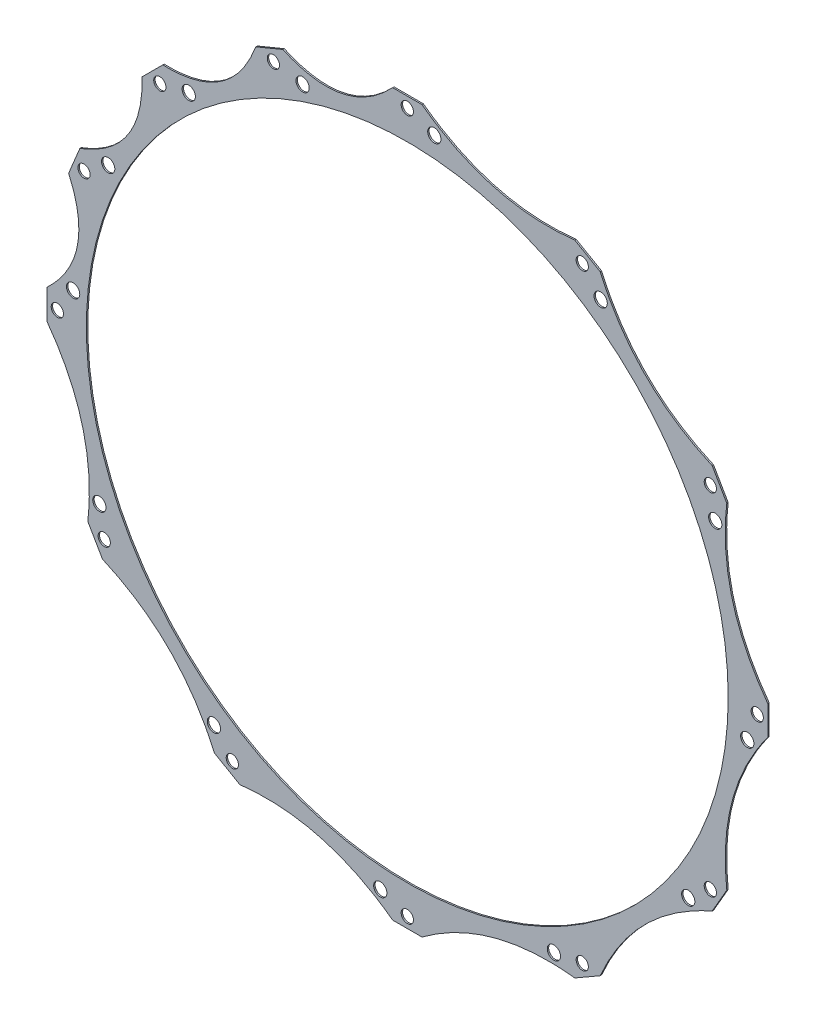
from build123d import *

# Parameters (mm, degrees)
SKETCH4_R           = 169.4688
SKETCH4_R_2         = 3.2385
BOSS_EXTRUDE2_DEPTH = 0.75
SKETCH8_R           = 3.5
CUT_EXTRUDE2_DEPTH  = 1.7500001


with BuildPart() as part:
    # Sketch4 → Boss-Extrude2 (new body)
    with BuildSketch(Plane.XY):
        with BuildLine():
            Line((-7.735342369, 190.342886598), (7.735342369, 190.342886598))
            add(Edge.make_bspline(
                [(7.735342369, 190.342886598), (43.849986057, 163.650375876), (88.472440301, 168.709446408)],
                knots=[0, 0, 0, 1, 1, 1], degree=2))
            Line((88.472440301, 168.709446408), (101.870446297, 160.974104039))
            add(Edge.make_bspline(
                [(101.870446297, 160.974104039), (119.800389819, 119.800389819), (160.974104039, 101.870446297)],
                knots=[0, 0, 0, 1, 1, 1], degree=2))
            Line((160.974104039, 101.870446297), (168.709446408, 88.472440301))
            add(Edge.make_bspline(
                [(168.709446408, 88.472440301), (163.650375876, 43.849986057), (190.342886598, 7.735342369)],
                knots=[0, 0, 0, 1, 1, 1], degree=2))
            Line((190.342886598, 7.735342369), (190.342886598, -7.735342369))
            add(Edge.make_bspline(
                [(190.342886598, -7.735342369), (163.650375876, -43.849986057), (168.709446408, -88.472440301)],
                knots=[0, 0, 0, 1, 1, 1], degree=2))
            Line((168.709446408, -88.472440301), (160.974104039, -101.870446297))
            add(Edge.make_bspline(
                [(160.974104039, -101.870446297), (119.800389819, -119.800389819), (101.870446297, -160.974104039)],
                knots=[0, 0, 0, 1, 1, 1], degree=2))
            Line((101.870446297, -160.974104039), (88.472440301, -168.709446408))
            add(Edge.make_bspline(
                [(88.472440301, -168.709446408), (43.849986057, -163.650375876), (7.735342369, -190.342886598)],
                knots=[0, 0, 0, 1, 1, 1], degree=2))
            Line((7.735342369, -190.342886598), (-7.735342369, -190.342886598))
            add(Edge.make_bspline(
                [(-7.735342369, -190.342886598), (-43.849986057, -163.650375876), (-88.472440301, -168.709446408)],
                knots=[0, 0, 0, 1, 1, 1], degree=2))
            Line((-88.472440301, -168.709446408), (-101.870446297, -160.974104039))
            add(Edge.make_bspline(
                [(-101.870446297, -160.974104039), (-119.800389819, -119.800389819), (-160.974104039, -101.870446297)],
                knots=[0, 0, 0, 1, 1, 1], degree=2))
            Line((-160.974104039, -101.870446297), (-168.709446408, -88.472440301))
            add(Edge.make_bspline(
                [(-168.709446408, -88.472440301), (-163.650375876, -43.849986057), (-190.342886598, -7.735342369)],
                knots=[0, 0, 0, 1, 1, 1], degree=2))
            Line((-190.342886598, -7.735342369), (-190.342886598, 7.735342369))
            add(Edge.make_bspline(
                [(-190.342886598, 7.735342369), (-163.877360858, 32.597233808), (-178.814084455, 65.694544678)],
                knots=[0, 0, 0, 1, 1, 1], degree=2))
            Line((-178.814084455, 65.694544678), (-172.893709719, 79.987593661))
            add(Edge.make_bspline(
                [(-172.893709719, 79.987593661), (-138.92851822, 92.829068072), (-140.062458908, 129.12303282)],
                knots=[0, 0, 0, 1, 1, 1], degree=2))
            Line((-140.062458908, 129.12303282), (-129.12303282, 140.062458908))
            add(Edge.make_bspline(
                [(-129.12303282, 140.062458908), (-92.829068072, 138.92851822), (-79.987593661, 172.893709719)],
                knots=[0, 0, 0, 1, 1, 1], degree=2))
            Line((-79.987593661, 172.893709719), (-65.694544678, 178.814084455))
            add(Edge.make_bspline(
                [(-65.694544678, 178.814084455), (-32.597233808, 163.877360858), (-7.735342369, 190.342886598)],
                knots=[0, 0, 0, 1, 1, 1], degree=2))
        make_face()
        Circle(SKETCH4_R, mode=Mode.SUBTRACT)
        with Locations((0, 184.785)):
            Circle(SKETCH4_R_2, mode=Mode.SUBTRACT)
        with Locations((-160.028504238, -92.3925)):
            Circle(SKETCH4_R_2, mode=Mode.SUBTRACT)
        with Locations((-92.3925, -160.028504238)):
            Circle(SKETCH4_R_2, mode=Mode.SUBTRACT)
        with Locations((0, -184.785)):
            Circle(SKETCH4_R_2, mode=Mode.SUBTRACT)
        with Locations((92.3925, -160.028504238)):
            Circle(SKETCH4_R_2, mode=Mode.SUBTRACT)
        with Locations((160.028504238, -92.3925)):
            Circle(SKETCH4_R_2, mode=Mode.SUBTRACT)
        with Locations((184.785, 0)):
            Circle(SKETCH4_R_2, mode=Mode.SUBTRACT)
        with Locations((160.028504238, 92.3925)):
            Circle(SKETCH4_R_2, mode=Mode.SUBTRACT)
        with Locations((92.3925, 160.028504238)):
            Circle(SKETCH4_R_2, mode=Mode.SUBTRACT)
        with Locations((-70.71415805, 170.719079415)):
            Circle(SKETCH4_R_2, mode=Mode.SUBTRACT)
        with Locations((-130.662726562, 130.662726562)):
            Circle(SKETCH4_R_2, mode=Mode.SUBTRACT)
        with Locations((-170.719079415, 70.71415805)):
            Circle(SKETCH4_R_2, mode=Mode.SUBTRACT)
        with Locations((-184.785, 0)):
            Circle(SKETCH4_R_2, mode=Mode.SUBTRACT)
    extrude(amount=BOSS_EXTRUDE2_DEPTH)

    # Sketch8 → Cut-Extrude2 (cut, through all)
    with BuildSketch(Plane.XY.offset(0.75)):
        with Locations((14.2615, 179.5235)):
            Circle(SKETCH8_R)
        with Locations((-176.455298363, 13.2615)):
            Circle(SKETCH8_R)
        with Locations((102.112571296, 148.341161576)):
            Circle(SKETCH8_R)
        with Locations((162.602661576, 77.410928704)):
            Circle(SKETCH8_R)
        with Locations((179.5235, -14.2615)):
            Circle(SKETCH8_R)
        with Locations((148.341161576, -102.112571296)):
            Circle(SKETCH8_R)
        with Locations((77.410928704, -162.602661576)):
            Circle(SKETCH8_R)
        with Locations((-14.2615, -179.5235)):
            Circle(SKETCH8_R)
        with Locations((-102.112571296, -148.341161576)):
            Circle(SKETCH8_R)
        with Locations((-162.602661576, -77.410928704)):
            Circle(SKETCH8_R)
        with Locations((-157.948482222, 79.778547657)):
            Circle(SKETCH8_R)
        with Locations((-115.39544147, 134.150034627)):
            Circle(SKETCH8_R)
        with Locations((-55.274490816, 168.098394899)):
            Circle(SKETCH8_R)
    extrude(amount=-CUT_EXTRUDE2_DEPTH, mode=Mode.SUBTRACT)


solid = part.part
